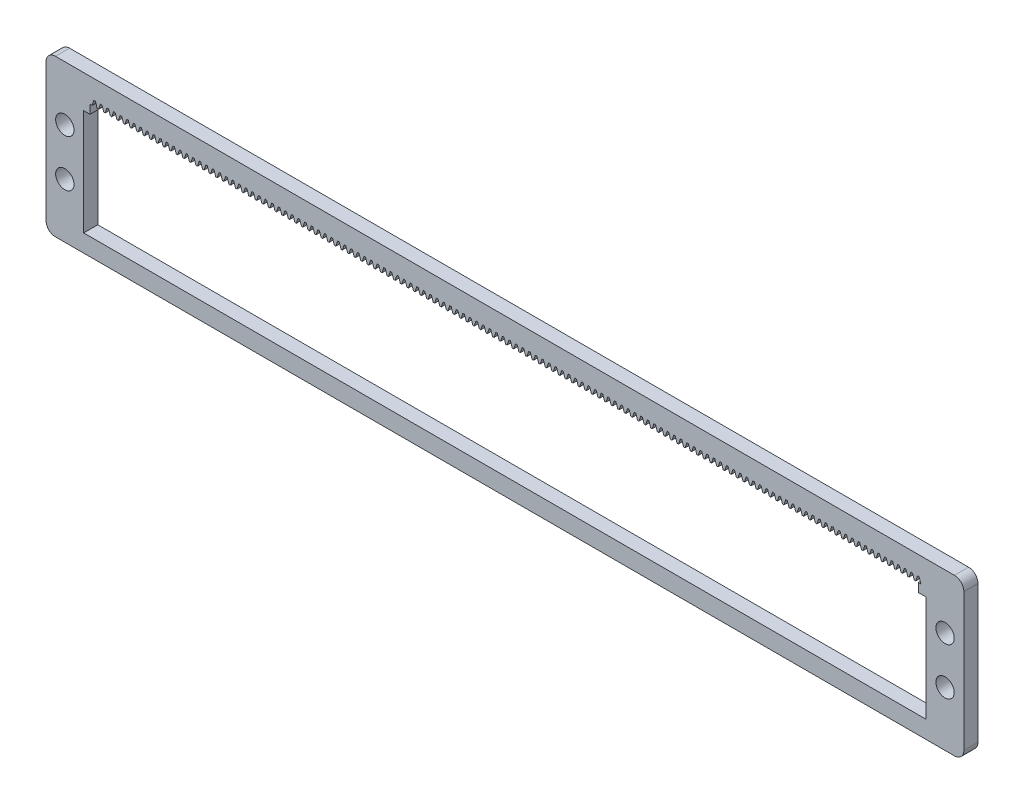
from build123d import *

# Parameters (mm, degrees)
BOSS_EXTRUDE1_DEPTH = 3
SKETCH2_W           = 179
SKETCH2_H           = 22.5
CUT_EXTRUDE1_DEPTH  = 4
SKETCH3_W           = 175.97
SKETCH3_H           = 1.85
CUT_EXTRUDE2_DEPTH  = 4
CUT_EXTRUDE4_DEPTH  = 4
LPATTERN1_COUNT     = 126
LPATTERN1_PITCH     = 1.4
SKETCH5_R           = 1.95
CUT_EXTRUDE5_DEPTH  = 10


with BuildPart() as part:
    # Sketch1 → Boss-Extrude1 (new body)
    with BuildSketch(Plane.XY):
        with BuildLine():
            Line((2, 0), (193, 0))
            ThreePointArc((193, 0), (194.414213562, -0.585786438), (195, -2))
            Line((195, -2), (195, -31.22))
            ThreePointArc((195, -31.22), (194.414213562, -32.634213562), (193, -33.22))
            Line((193, -33.22), (2, -33.22))
            ThreePointArc((2, -33.22), (0.585786438, -32.634213562), (0, -31.22))
            Line((0, -31.22), (0, -2))
            ThreePointArc((0, -2), (0.585786438, -0.585786438), (2, 0))
        make_face()
    extrude(amount=BOSS_EXTRUDE1_DEPTH)

    # Sketch2 → Cut-Extrude1 (cut, through all)
    with BuildSketch(Plane.XY.offset(3)):
        with Locations((97.5, -18.25)):
            Rectangle(SKETCH2_W, SKETCH2_H)
    extrude(amount=-CUT_EXTRUDE1_DEPTH, mode=Mode.SUBTRACT)

    # Sketch3 → Cut-Extrude2 (cut, through all)
    with BuildSketch(Plane.XY.offset(3)):
        with Locations((97.335, -6.075)):
            Rectangle(SKETCH3_W, SKETCH3_H)
    extrude(amount=-CUT_EXTRUDE2_DEPTH, mode=Mode.SUBTRACT)

    # Sketch4 → Cut-Extrude4 (cut, through all)
    with BuildSketch(Plane.XY.offset(3)):
        Polygon((185.485, -4.011755738), (185.865, -5.15), (184.775, -5.15), (185.155, -4.011755738), align=None)
    cut_extrude4 = extrude(amount=-CUT_EXTRUDE4_DEPTH, mode=Mode.SUBTRACT)

    # LPattern1: Cut-Extrude4 ×126
    with Locations(*[(-i * LPATTERN1_PITCH, 0, 0) for i in range(1, LPATTERN1_COUNT)]):
        add(cut_extrude4, mode=Mode.SUBTRACT)

    # Sketch5 → Cut-Extrude5 (cut)
    with BuildSketch(Plane.XY.offset(3)):
        with Locations((4, -11.61)):
            Circle(SKETCH5_R)
        with Locations((4, -21.61)):
            Circle(SKETCH5_R)
        with Locations((191, -11.61)):
            Circle(SKETCH5_R)
        with Locations((191, -21.61)):
            Circle(SKETCH5_R)
    extrude(amount=-CUT_EXTRUDE5_DEPTH, mode=Mode.SUBTRACT)


solid = part.part
